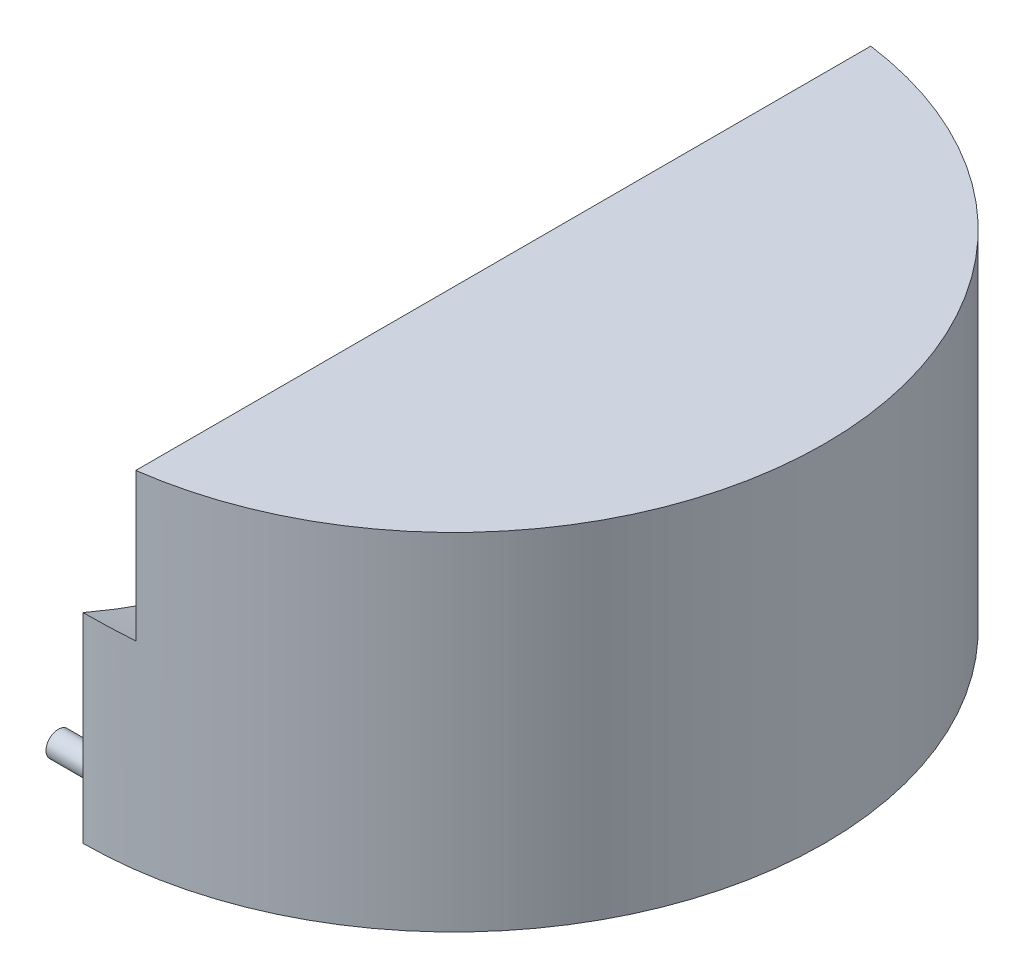
from build123d import *

# Parameters (mm, degrees)
BOSS_EXTRUDE2_DEPTH = 100
SKETCH3_W           = 11
SKETCH3_H           = 22
SKETCH4_R           = 1
CUT_EXTRUDE1_DEPTH  = 2
SKETCH5_R           = 1
CUT_EXTRUDE2_DEPTH  = 2
CIRPATTERN1_COUNT   = 4
SKETCH8_R           = 2.5
SKETCH8_W           = 20
SKETCH8_H           = 5
BOSS_EXTRUDE3_DEPTH = 10
SKETCH6_W           = 10
SKETCH6_H           = 190
BOSS_EXTRUDE4_DEPTH = 115
SKETCH10_W          = 10
SKETCH10_H          = 190
SKETCH11_R          = 1
CUT_EXTRUDE3_DEPTH  = 2
SKETCH12_R          = 75
CUT_EXTRUDE4_DEPTH  = 30


with BuildPart() as part:
    # Sketch1 → Boss-Extrude2 (new body)
    with BuildSketch(Plane(origin=(0, 0, 0), x_dir=(1, 0, 0), z_dir=(0, 1, 0))):
        with BuildLine():
            ThreePointArc((75, 0), (53.033008589, 53.033008589), (0, 75))
            Line((0, 75), (0, -75))
            ThreePointArc((0, -75), (53.033008589, -53.033008589), (75, 0))
        make_face()
    extrude(amount=BOSS_EXTRUDE2_DEPTH)

    # Sketch3 → Cut-Revolve3 (revolve, cut)
    with BuildSketch(Plane(origin=(0, 0, 0), x_dir=(-1, 0, 0), z_dir=(0, -1, 0))):
        with Locations((-59.5, 11)):
            Rectangle(SKETCH3_W, SKETCH3_H)
    cut_revolve3 = revolve(axis=Axis((0, 0, 0), (1, 0, 0)), mode=Mode.SUBTRACT)

    # Sketch4 → Cut-Extrude1 (cut)
    with BuildSketch(Plane.ZY.offset(-65)):
        Circle(SKETCH4_R)
    cut_extrude1 = extrude(amount=-CUT_EXTRUDE1_DEPTH, mode=Mode.SUBTRACT)

    # Sketch5 → Cut-Extrude2 (cut)
    with BuildSketch(Plane(origin=(54, 0, 0), x_dir=(0, 0, -1), z_dir=(1, 0, 0))):
        Circle(SKETCH5_R)
    cut_extrude2 = extrude(amount=-CUT_EXTRUDE2_DEPTH, mode=Mode.SUBTRACT)

    # CirPattern1: Cut-Revolve3, Cut-Extrude1, Cut-Extrude2 ×4 about axis
    cirpattern1_axis = Axis((0, 0, 0), (0, 1, 0))
    add([cut_revolve3.rotate(cirpattern1_axis, i * 360 / CIRPATTERN1_COUNT) for i in range(1, CIRPATTERN1_COUNT)], mode=Mode.SUBTRACT)
    add([cut_extrude1.rotate(cirpattern1_axis, i * 360 / CIRPATTERN1_COUNT) for i in range(1, CIRPATTERN1_COUNT)], mode=Mode.SUBTRACT)
    add([cut_extrude2.rotate(cirpattern1_axis, i * 360 / CIRPATTERN1_COUNT) for i in range(1, CIRPATTERN1_COUNT)], mode=Mode.SUBTRACT)

    # Sketch8 → Boss-Extrude3 (add)
    with BuildSketch(Plane.ZY):
        with Locations(Location((-70, 10, 0), (0, 0, 180))):
            Circle(SKETCH8_R)
        with Locations(Location((70, 10, 0), (0, 0, 180))):
            Circle(SKETCH8_R)
        with Locations((-30, 2.5)):
            Rectangle(SKETCH8_W, SKETCH8_H)
        with Locations((30, 2.5)):
            Rectangle(SKETCH8_W, SKETCH8_H)
    extrude(amount=BOSS_EXTRUDE3_DEPTH)

    # Sketch6 → Boss-Extrude4 (add)
    with BuildSketch(Plane(origin=(0, 100, 0), x_dir=(1, 0, 0), z_dir=(0, 1, 0))):
        with Locations((5, -95)):
            Rectangle(SKETCH6_W, SKETCH6_H)
    extrude(amount=BOSS_EXTRUDE4_DEPTH)

    # Sketch10 → Cut-Revolve4 (revolve, cut)
    with BuildSketch(Plane(origin=(0, 215, 0), x_dir=(1, 0, 0), z_dir=(0, 1, 0))):
        with Locations((5, -95)):
            Rectangle(SKETCH10_W, SKETCH10_H)
    revolve(axis=Axis((10, 215, 0), (-1, 0, 0)), mode=Mode.SUBTRACT)


with BuildPart() as cut_revolve4_kept_piece:
    # of the separate pieces the step leaves, the one the design keeps (cut_revolve4_pieces_kept)
    add(part.part.solids().sort_by_distance((0, 0, 75))[0])

    # Sketch11 → Cut-Extrude3 (cut)
    with BuildSketch(Plane.ZY.offset(-10)):
        with Locations((-0.669656263, 47.5)):
            Circle(SKETCH11_R)
        with Locations((-65.669656263, 60.5)):
            Circle(SKETCH11_R)
        with Locations((64.330343737, 60.5)):
            Circle(SKETCH11_R)
    extrude(amount=-CUT_EXTRUDE3_DEPTH, mode=Mode.SUBTRACT)

    # Sketch12 → Cut-Extrude4 (cut)
    with BuildSketch(Plane(origin=(0, 100, 0), x_dir=(1, 0, 0), z_dir=(0, 1, 0))):
        Circle(SKETCH12_R)
    extrude(amount=-CUT_EXTRUDE4_DEPTH, mode=Mode.SUBTRACT)


solid = cut_revolve4_kept_piece.part
